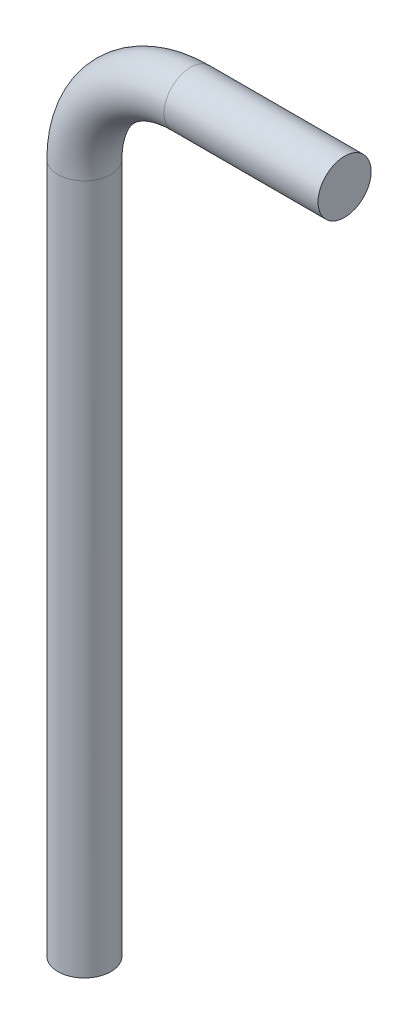
from build123d import *

# Parameters (mm, degrees)
SKETCH3_R = 2.5


with BuildPart() as part:
    # Sweep2: sweep along a path in Sketch5
    with BuildLine(Plane.XY) as sweep2_path:
        Line((0, 0), (0, 65))
        ThreePointArc((0, 65), (2.928932188, 72.071067812), (10, 75))
        Line((10, 75), (24.49747468, 75))
    # Sketch3 → Sweep2 (sweep)
    with BuildSketch(Plane(origin=(0, 0, 0), x_dir=(1, 0, 0), z_dir=(0, 1, 0))):
        Circle(SKETCH3_R)
    sweep(path=sweep2_path.line)


solid = part.part
